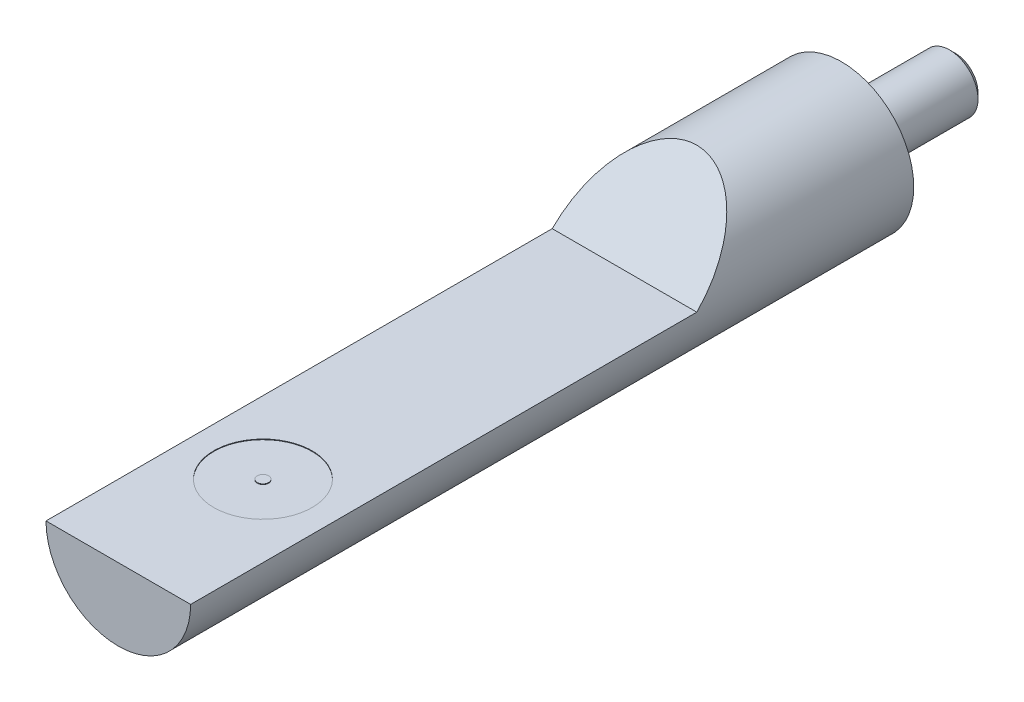
from build123d import *

# Parameters (mm, degrees)
SKETCH1_R           = 3.175
EXTRUDE1_DEPTH      = 31.75
SKETCH2_R           = 1.25
EXTRUDE2_DEPTH      = 5
CHAMFER1_SIZE       = 0.254
EXTRUDE3_DEPTH      = 4.175
EXTRUDE3_DEPTH_BACK = 4.175
SKETCH4_R           = 2.159
SKETCH4_R_2         = 0.254
EXTRUDE4_DEPTH      = 0.0254


with BuildPart() as part:
    # Sketch1 → Extrude1 (new body)
    with BuildSketch(Plane.XY):
        Circle(SKETCH1_R)
    extrude(amount=EXTRUDE1_DEPTH)

    # Sketch2 → Extrude2 (add)
    with BuildSketch(Plane(origin=(0, 0, 0), x_dir=(-1, 0, 0), z_dir=(0, 0, -1))):
        with Locations(Location((0, 0, 0), (0, 0, 180))):  # turned: the seam where the file's is
            Circle(SKETCH2_R)
    extrude(amount=EXTRUDE2_DEPTH)

    # Chamfer1
    chamfer1_edges = [part.edges().sort_by_distance(p)[0] for p in [
        (-1.25, 0, -5),
    ]]
    chamfer(chamfer1_edges, length=CHAMFER1_SIZE)

    # Sketch3 → Extrude3 (cut, two sides)
    with BuildSketch(Plane(origin=(0, 0, 0), x_dir=(0, 0, -1), z_dir=(1, 0, 0))) as extrude3_sk:
        Polygon((-31.75, 0), (-9.525, 0), (-6.35, 3.175), (-31.75, 3.175), align=None)
    extrude(amount=EXTRUDE3_DEPTH, mode=Mode.SUBTRACT)
    extrude(extrude3_sk.sketch, amount=-EXTRUDE3_DEPTH_BACK, mode=Mode.SUBTRACT)

    # Sketch4 → Extrude4 (cut)
    with BuildSketch(Plane(origin=(0, 0, 0), x_dir=(1, 0, 0), z_dir=(0, 1, 0))):
        with Locations(Location((0, -25.4, 0), (0, 0, 270))):  # turned: the seam where the file's is
            Circle(SKETCH4_R)
        with Locations(Location((0, -25.4, 0), (0, 0, 270))):  # turned: the seam where the file's is
            Circle(SKETCH4_R_2, mode=Mode.SUBTRACT)
    extrude(amount=-EXTRUDE4_DEPTH, mode=Mode.SUBTRACT)


solid = part.part
